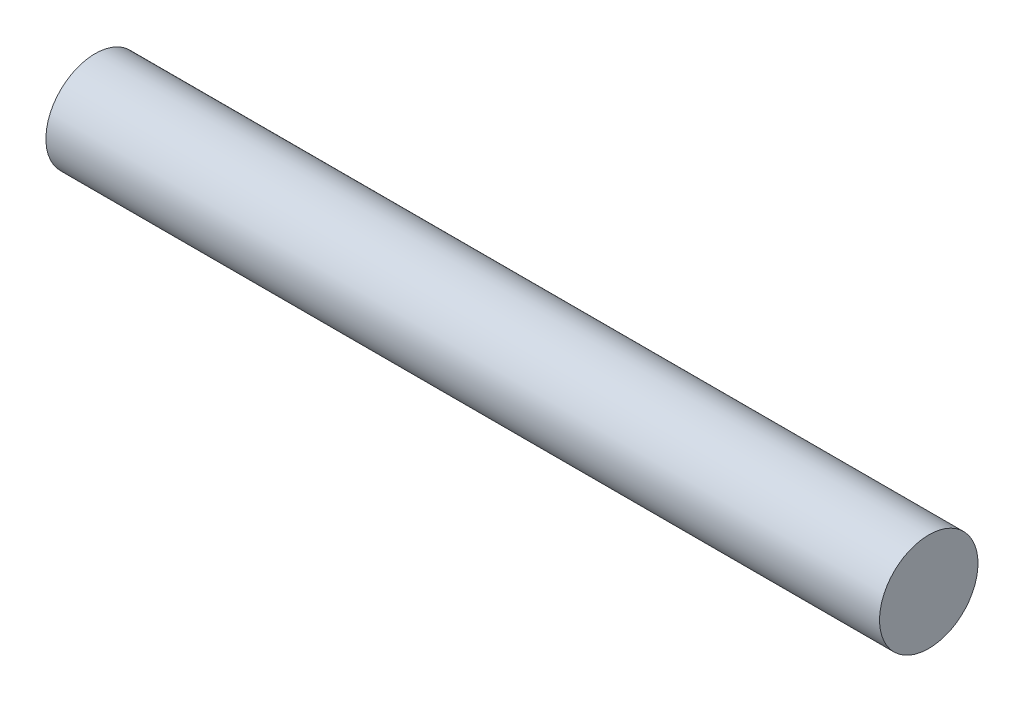
from build123d import *

# Parameters (mm, degrees)
SKETCH1_R           = 0.15
BOSS_EXTRUDE1_DEPTH = 2.54


with BuildPart() as part:
    # Sketch1 → Boss-Extrude1 (new body)
    with BuildSketch(Plane(origin=(0, 0, 0), x_dir=(0, 0, -1), z_dir=(1, 0, 0))):
        Circle(SKETCH1_R)
    extrude(amount=BOSS_EXTRUDE1_DEPTH)


solid = part.part
